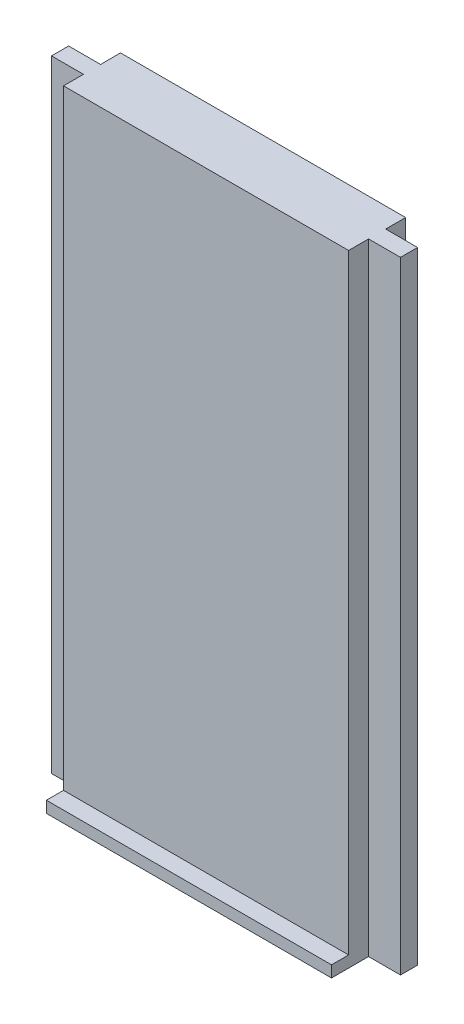
from build123d import *

# Parameters (mm, degrees)
BOSS_EXTRUDE1_DEPTH = 54.5
SKETCH2_W           = 25
SKETCH2_H           = 1.5
BOSS_EXTRUDE2_DEPTH = 1


with BuildPart() as part:
    # Sketch1 → Boss-Extrude1 (new body)
    with BuildSketch(Plane(origin=(0, 0, 0), x_dir=(1, 0, 0), z_dir=(0, 1, 0))):
        Polygon((-12.5, 0.75), (-12.5, 2.5), (12.5, 2.5), (12.5, 0.75), (15.3, 0.75), (15.3, -0.75), (12.5, -0.75), (12.5, -2.5), (-12.5, -2.5), (-12.5, -0.75), (-15.3, -0.75), (-15.3, 0.75), align=None)
    extrude(amount=BOSS_EXTRUDE1_DEPTH)

    # Sketch2 → Boss-Extrude2 (add)
    with BuildSketch(Plane(origin=(0, 0, 0), x_dir=(1, 0, 0), z_dir=(0, 1, 0))):
        with Locations((0, -3.25)):
            Rectangle(SKETCH2_W, SKETCH2_H)
    extrude(amount=BOSS_EXTRUDE2_DEPTH)


solid = part.part
